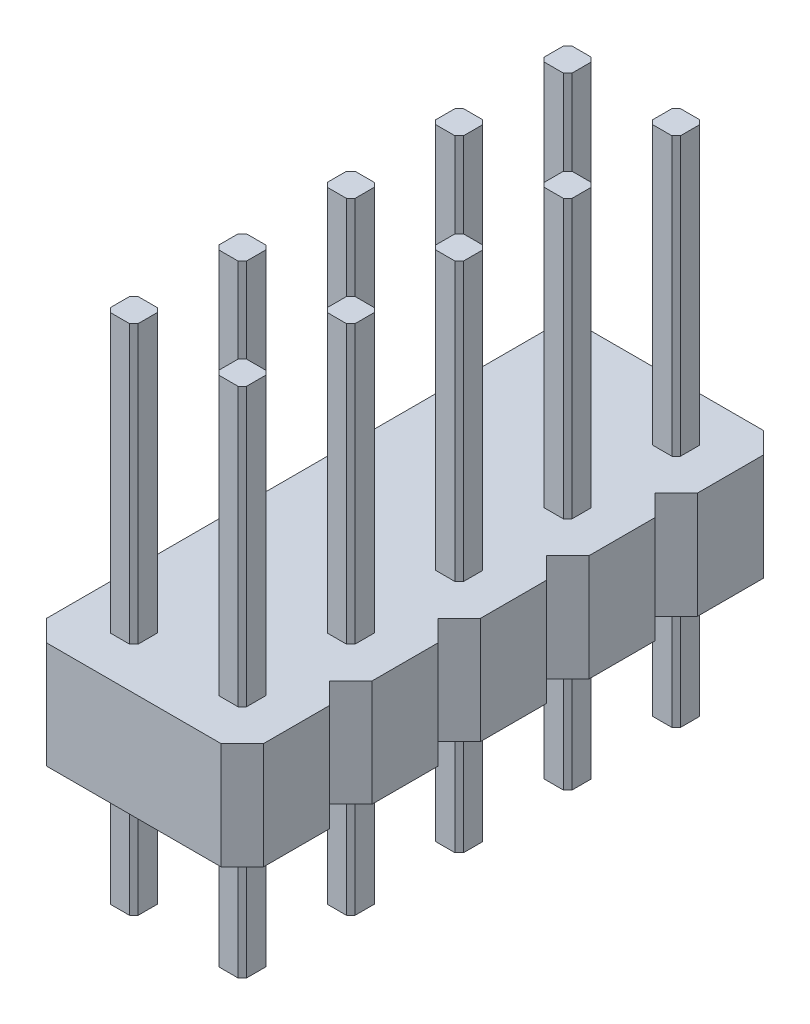
from build123d import *

# Parameters (mm, degrees)
BOSS_EXTRUDE1_DEPTH = 12
LPATTERN1_COUNT     = 2
LPATTERN1_PITCH     = 2.54
BOSS_EXTRUDE2_DEPTH = 2.5
LPATTERN2_COUNT     = 5
LPATTERN2_PITCH     = 2.54


with BuildPart() as part:
    # Sketch1 → Boss-Extrude1 (new body)
    with BuildSketch(Plane(origin=(0, 0, 0), x_dir=(1, 0, 0), z_dir=(0, 1, 0))):
        Polygon((-0.325, 0.225), (-0.225, 0.325), (0.225, 0.325), (0.325, 0.225), (0.325, -0.225), (0.225, -0.325), (-0.225, -0.325), (-0.325, -0.225), align=None)
    extrude(amount=BOSS_EXTRUDE1_DEPTH)


with BuildPart() as lpattern1_1:
    # LPattern1: pattern copy
    add(part.part.moved(Location(Vector(-1, 0, 0) * (1 * LPATTERN1_PITCH))))


with BuildPart() as part_1:
    add(part.part)

    add(lpattern1_1.part)  # Boss-Extrude2 merges LPattern1_1
    # Sketch2 → Boss-Extrude2 (add)
    with BuildSketch(Plane(origin=(0, 3, 0), x_dir=(-1, 0, 0), z_dir=(0, -1, 0))):
        Polygon((-1.27, 0.77), (-0.77, 1.27), (3.31, 1.27), (3.81, 0.77), (3.81, -0.77), (3.31, -1.27), (-0.77, -1.27), (-1.27, -0.77), align=None)
    extrude(amount=-BOSS_EXTRUDE2_DEPTH)


with BuildPart() as lpattern2_1:
    # LPattern2: pattern copy
    add(part_1.part.moved(Location(Vector(0, 0, -1) * (1 * LPATTERN2_PITCH))))


with BuildPart() as lpattern2_2:
    # LPattern2: pattern copy
    add(part_1.part.moved(Location(Vector(0, 0, -1) * (2 * LPATTERN2_PITCH))))


with BuildPart() as lpattern2_3:
    # LPattern2: pattern copy
    add(part_1.part.moved(Location(Vector(0, 0, -1) * (3 * LPATTERN2_PITCH))))


with BuildPart() as lpattern2_4:
    # LPattern2: pattern copy
    add(part_1.part.moved(Location(Vector(0, 0, -1) * (4 * LPATTERN2_PITCH))))


with BuildPart() as part_2:
    add(part_1.part)

    # Combine1: union LPattern2_1, LPattern2_2, LPattern2_3, LPattern2_4
    add(lpattern2_1.part)
    add(lpattern2_2.part)
    add(lpattern2_3.part)
    add(lpattern2_4.part)


solid = part_2.part
